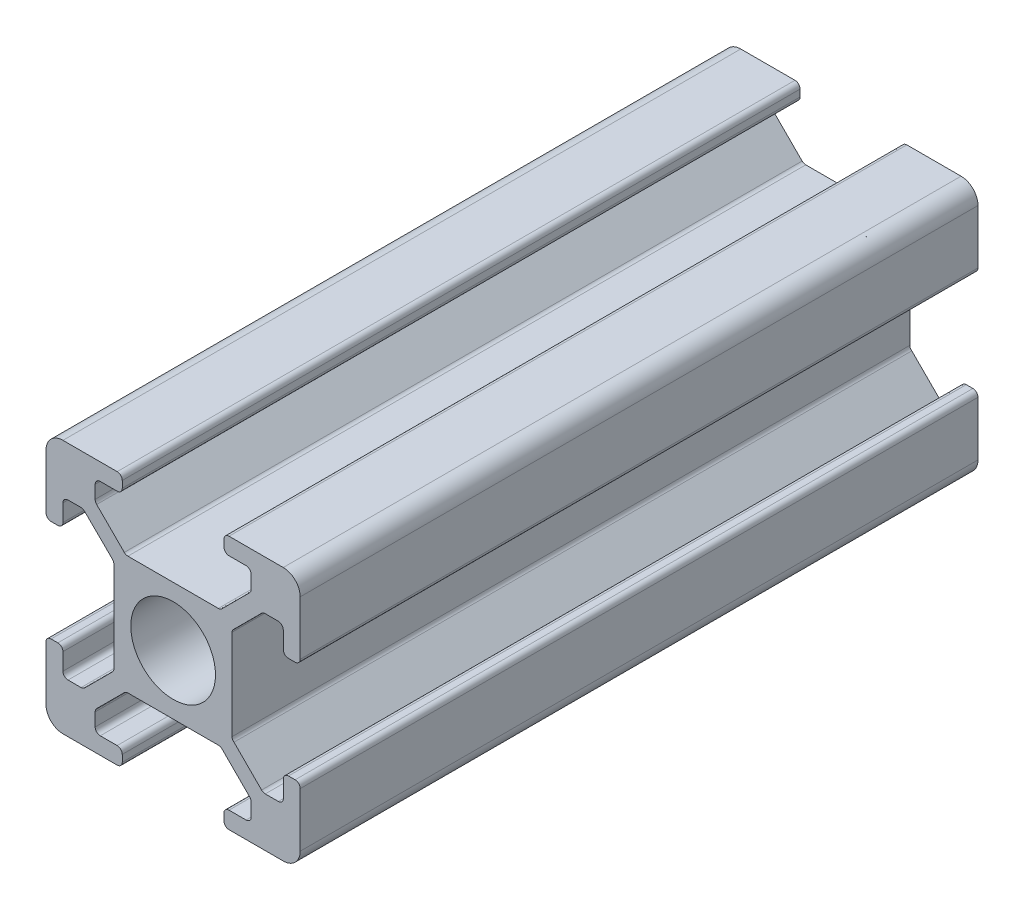
from build123d import *

# Parameters (mm, degrees)
SKETCH1_R           = 2.5
BOSS_EXTRUDE1_DEPTH = 40


with BuildPart() as part:
    # Sketch1 → Boss-Extrude1 (new body)
    with BuildSketch(Plane.XY):
        with BuildLine():
            Line((0.997149379, -0.010991612), (4.197149379, -0.010991612))
            ThreePointArc((4.197149379, -0.010991612), (4.409281413, 0.076876353), (4.497149379, 0.289008388))
            Line((4.497149379, 0.289008388), (4.497149379, 0.689008388))
            ThreePointArc((4.497149379, 0.689008388), (4.409281413, 0.901140422), (4.197149379, 0.989008388))
            Line((4.197149379, 0.989008388), (3.197149379, 0.989008388))
            ThreePointArc((3.197149379, 0.989008388), (2.985017344, 1.076876353), (2.897149379, 1.289008388))
            Line((2.897149379, 1.289008388), (2.897149379, 2.057637538))
            ThreePointArc((2.897149379, 2.057637538), (2.920422177, 2.174637797), (2.9866975, 2.273825827))
            Line((2.9866975, 2.273825827), (4.61806835, 3.905196677))
            ThreePointArc((4.61806835, 3.905196677), (4.71725638, 3.971472), (4.834256639, 3.994744798))
            Line((4.834256639, 3.994744798), (10.171514939, 3.994744798))
            ThreePointArc((10.171514939, 3.994744798), (10.288515198, 3.971472), (10.387703228, 3.905196677))
            Line((10.387703228, 3.905196677), (12.019074078, 2.273825827))
            ThreePointArc((12.019074078, 2.273825827), (12.085349401, 2.174637797), (12.1086222, 2.057637538))
            Line((12.1086222, 2.057637538), (12.1086222, 1.289008388))
            ThreePointArc((12.1086222, 1.289008388), (12.020754234, 1.076876353), (11.8086222, 0.989008388))
            Line((11.8086222, 0.989008388), (10.797149379, 0.989008388))
            ThreePointArc((10.797149379, 0.989008388), (10.585017344, 0.901140422), (10.497149379, 0.689008388))
            Line((10.497149379, 0.689008388), (10.497149379, 0.289008388))
            ThreePointArc((10.497149379, 0.289008388), (10.585017344, 0.076876353), (10.797149379, -0.010991612))
            Line((10.797149379, -0.010991612), (13.997149379, -0.010991612))
            ThreePointArc((13.997149379, -0.010991612), (14.70425616, 0.281901607), (14.997149379, 0.989008388))
            Line((14.997149379, 0.989008388), (14.997149379, 4.189008388))
            ThreePointArc((14.997149379, 4.189008388), (14.909281413, 4.401140422), (14.697149379, 4.489008388))
            Line((14.697149379, 4.489008388), (14.305261888, 4.489008388))
            ThreePointArc((14.305261888, 4.489008388), (14.093129854, 4.401140422), (14.005261888, 4.189008388))
            Line((14.005261888, 4.189008388), (14.005261888, 3.189008388))
            ThreePointArc((14.005261888, 3.189008388), (13.917393922, 2.976876353), (13.705261888, 2.889008388))
            Line((13.705261888, 2.889008388), (12.936632738, 2.889008388))
            ThreePointArc((12.936632738, 2.889008388), (12.819632479, 2.912281186), (12.720444449, 2.978556509))
            Line((12.720444449, 2.978556509), (11.089073599, 4.609927359))
            ThreePointArc((11.089073599, 4.609927359), (11.006246661, 4.70520219), (10.969948855, 4.826115648))
            Line((10.969948855, 4.826115648), (10.969948855, 10.163373948))
            ThreePointArc((10.969948855, 10.163373948), (11.00546556, 10.284783861), (11.087867966, 10.380761184))
            Line((11.087867966, 10.380761184), (12.719238816, 12.012132034))
            ThreePointArc((12.719238816, 12.012132034), (12.81656582, 12.07716386), (12.93137085, 12.1))
            Line((12.93137085, 12.1), (13.7, 12.1))
            ThreePointArc((13.7, 12.1), (13.912132034, 12.012132034), (14, 11.8))
            Line((14, 11.8), (14, 10.8))
            ThreePointArc((14, 10.8), (14.087867966, 10.587867966), (14.3, 10.5))
            Line((14.3, 10.5), (14.697149379, 10.5))
            ThreePointArc((14.697149379, 10.5), (14.909281413, 10.587867966), (14.997149379, 10.8))
            Line((14.997149379, 10.8), (14.997149379, 13.989008388))
            ThreePointArc((14.997149379, 13.989008388), (14.70425616, 14.696115169), (13.997149379, 14.989008388))
            Line((13.997149379, 14.989008388), (10.797149379, 14.989008388))
            ThreePointArc((10.797149379, 14.989008388), (10.585017344, 14.901140422), (10.497149379, 14.689008388))
            Line((10.497149379, 14.689008388), (10.497149379, 14.289008388))
            ThreePointArc((10.497149379, 14.289008388), (10.585017344, 14.076876353), (10.797149379, 13.989008388))
            Line((10.797149379, 13.989008388), (11.798829534, 13.989008388))
            ThreePointArc((11.798829534, 13.989008388), (12.010961569, 13.901140422), (12.098829534, 13.689008388))
            Line((12.098829534, 13.689008388), (12.098829534, 12.916322983))
            ThreePointArc((12.098829534, 12.916322983), (12.075993394, 12.801517953), (12.010961569, 12.704190949))
            Line((12.010961569, 12.704190949), (10.379590719, 11.072820099))
            ThreePointArc((10.379590719, 11.072820099), (10.282263714, 11.007788273), (10.167458684, 10.984952133))
            Line((10.167458684, 10.984952133), (4.830200384, 10.984952133))
            ThreePointArc((4.830200384, 10.984952133), (4.715395355, 11.007788273), (4.61806835, 11.072820099))
            Line((4.61806835, 11.072820099), (2.9866975, 12.704190949))
            ThreePointArc((2.9866975, 12.704190949), (2.920422177, 12.803378979), (2.897149379, 12.920379238))
            Line((2.897149379, 12.920379238), (2.897149379, 13.689008388))
            ThreePointArc((2.897149379, 13.689008388), (2.985017344, 13.901140422), (3.197149379, 13.989008388))
            Line((3.197149379, 13.989008388), (4.197149379, 13.989008388))
            ThreePointArc((4.197149379, 13.989008388), (4.409281413, 14.076876353), (4.497149379, 14.289008388))
            Line((4.497149379, 14.289008388), (4.497149379, 14.689008388))
            ThreePointArc((4.497149379, 14.689008388), (4.409281413, 14.901140422), (4.197149379, 14.989008388))
            Line((4.197149379, 14.989008388), (0.997149379, 14.989008388))
            ThreePointArc((0.997149379, 14.989008388), (0.290042597, 14.696115169), (-0.002850621, 13.989008388))
            Line((-0.002850621, 13.989008388), (-0.002850621, 10.789008388))
            ThreePointArc((-0.002850621, 10.789008388), (0.085017344, 10.576876353), (0.297149379, 10.489008388))
            Line((0.297149379, 10.489008388), (0.697149379, 10.489008388))
            ThreePointArc((0.697149379, 10.489008388), (0.909281413, 10.576876353), (0.997149379, 10.789008388))
            Line((0.997149379, 10.789008388), (0.997149379, 11.790199043))
            ThreePointArc((0.997149379, 11.790199043), (1.085017344, 12.002331078), (1.297149379, 12.090199043))
            Line((1.297149379, 12.090199043), (2.057928823, 12.090199043))
            ThreePointArc((2.057928823, 12.090199043), (2.174143192, 12.067250491), (2.272911478, 12.001849869))
            Line((2.272911478, 12.001849869), (3.912132034, 10.380761184))
            ThreePointArc((3.912132034, 10.380761184), (3.97928656, 10.281159192), (4.002885789, 10.163373948))
            Line((4.002885789, 10.163373948), (4.002885789, 4.826115648))
            ThreePointArc((4.002885789, 4.826115648), (3.979612991, 4.709115389), (3.913337668, 4.609927359))
            Line((3.913337668, 4.609927359), (2.281966818, 2.978556509))
            ThreePointArc((2.281966818, 2.978556509), (2.182778788, 2.912281186), (2.065778529, 2.889008388))
            Line((2.065778529, 2.889008388), (1.297149379, 2.889008388))
            ThreePointArc((1.297149379, 2.889008388), (1.085017344, 2.976876353), (0.997149379, 3.189008388))
            Line((0.997149379, 3.189008388), (0.997149379, 4.189008388))
            ThreePointArc((0.997149379, 4.189008388), (0.909281413, 4.401140422), (0.697149379, 4.489008388))
            Line((0.697149379, 4.489008388), (0.297149379, 4.489008388))
            ThreePointArc((0.297149379, 4.489008388), (0.085017344, 4.401140422), (-0.002850621, 4.189008388))
            Line((-0.002850621, 4.189008388), (-0.002850621, 0.989008388))
            ThreePointArc((-0.002850621, 0.989008388), (0.290042597, 0.281901607), (0.997149379, -0.010991612))
        make_face()
        with Locations((7.5, 7.5)):
            Circle(SKETCH1_R, mode=Mode.SUBTRACT)
    extrude(amount=BOSS_EXTRUDE1_DEPTH)


solid = part.part
